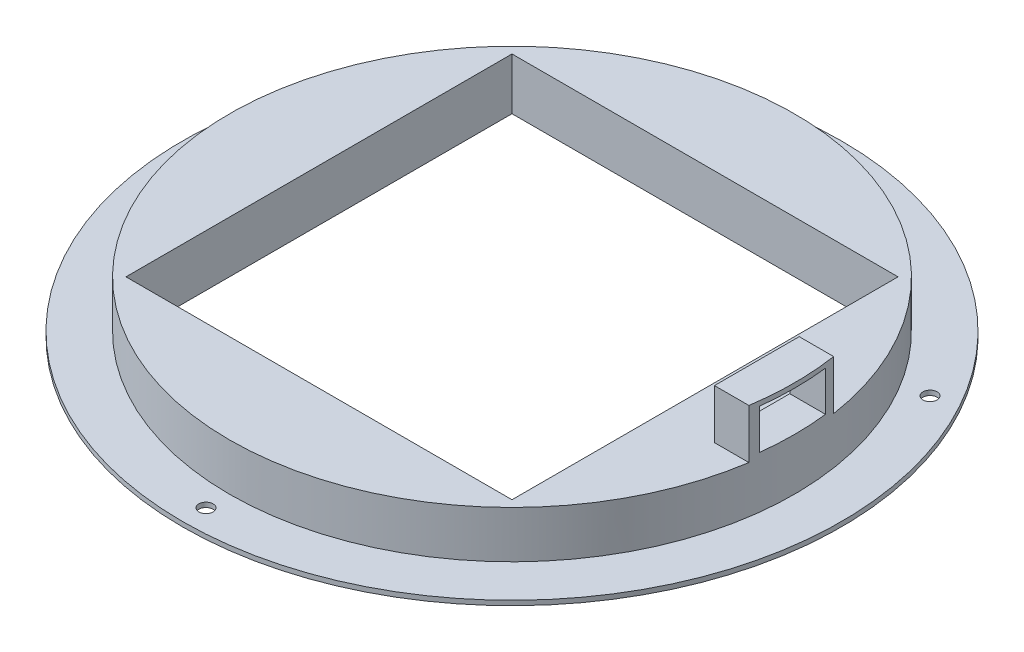
from build123d import *

# Parameters (mm, degrees)
CROQUIS2_W              = 82
CROQUIS2_H              = 82
CORTAR_EXTRUIR1_DEPTH   = 11.5
SALIENTE_EXTRUIR1_DEPTH = 10.5
CROQUIS4_W              = 14
CROQUIS4_H              = 8.5
CORTAR_EXTRUIR2_DEPTH   = 10.5
CROQUIS5_R              = 1.5
CORTAR_EXTRUIR3_DEPTH   = 10


with BuildPart() as part:
    # Croquis1 → Revolución1 (revolve)
    with BuildSketch(Plane.XY):
        Polygon((-96.901642817, 61.97611702), (-96.901642817, 60.97611702), (-67.901642817, 60.97611702), (-67.901642817, 61.97611702), (-67.901642817, 71.97611702), (-86.901642817, 71.97611702), (-86.901642817, 61.97611702), align=None)
    revolve(axis=Axis((-26.901642817, 46.97611702, 0), (0, -1, 0)))

    # Croquis2 → Cortar-Extruir1 (cut)
    with BuildSketch(Plane(origin=(0, 71.97611702, 0), x_dir=(1, 0, 0), z_dir=(0, 1, 0))):
        with Locations((-26.901642817, 0)):
            Rectangle(CROQUIS2_W, CROQUIS2_H)
    extrude(amount=-CORTAR_EXTRUIR1_DEPTH, mode=Mode.SUBTRACT)

    # Croquis3 → Saliente-Extruir1 (add)
    with BuildSketch(Plane(origin=(0, 71.97611702, 0), x_dir=(1, 0, 0), z_dir=(0, 1, 0))):
        with BuildLine():
            Line((32.419516983, 9), (25.098357183, 9))
            Line((25.098357183, 9), (25.098357183, -9))
            Line((25.098357183, -9), (32.419516983, -9))
            ThreePointArc((32.419516983, -9), (33.098357183, 0), (32.419516983, 9))
        make_face()
    extrude(amount=SALIENTE_EXTRUIR1_DEPTH)

    # Croquis4 → Cortar-Extruir2 (cut)
    with BuildSketch(Plane.ZY.offset(-25.098357183)):
        with Locations((0, 77.22611702)):
            Rectangle(CROQUIS4_W, CROQUIS4_H)
    extrude(amount=-CORTAR_EXTRUIR2_DEPTH, mode=Mode.SUBTRACT)

    # Croquis5 → Cortar-Extruir3 (cut)
    with BuildSketch(Plane(origin=(0, 61.97611702, 0), x_dir=(1, 0, 0), z_dir=(0, 1, 0))):
        with Locations((-26.901642817, -65)):
            Circle(CROQUIS5_R)
        with Locations((-83.193294063, 32.5)):
            Circle(CROQUIS5_R)
        with Locations((29.390008429, 32.5)):
            Circle(CROQUIS5_R)
    extrude(amount=-CORTAR_EXTRUIR3_DEPTH, mode=Mode.SUBTRACT)


solid = part.part
